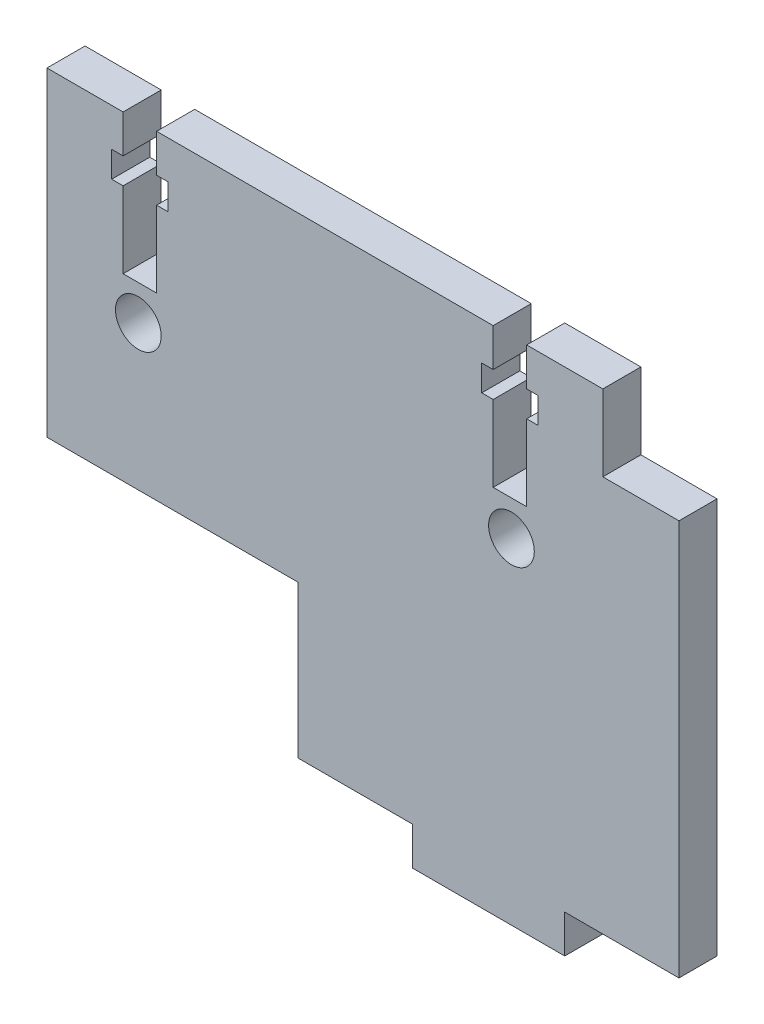
from build123d import *

# Parameters (mm, degrees)
BOSS_EXTRUDE1_DEPTH = 5
SKETCH2_W           = 33
SKETCH2_H           = 20
SKETCH2_W_2         = 10
SKETCH2_H_2         = 10
CUT_EXTRUDE1_DEPTH  = 5
CUT_EXTRUDE2_DEPTH  = 10
SKETCH4_R           = 3
CUT_EXTRUDE3_DEPTH  = 10


with BuildPart() as part:
    # Sketch1 → Boss-Extrude1 (new body)
    with BuildSketch(Plane.XY):
        Polygon((26.5, -31), (26.5, -36), (6.5, -36), (6.5, -31), (-41.5, -31), (-41.5, 31), (41.5, 31), (41.5, -31), align=None)
    extrude(amount=BOSS_EXTRUDE1_DEPTH)

    # Sketch2 → Cut-Extrude1 (cut)
    with BuildSketch(Plane(origin=(0, 0, 0), x_dir=(-1, 0, 0), z_dir=(0, 0, -1))):
        with Locations((25, -21)):
            Rectangle(SKETCH2_W, SKETCH2_H)
        with Locations((-36.5, 26)):
            Rectangle(SKETCH2_W_2, SKETCH2_H_2)
    extrude(amount=-CUT_EXTRUDE1_DEPTH, mode=Mode.SUBTRACT)

    # Sketch3 → Cut-Extrude2 (cut)
    with BuildSketch(Plane(origin=(0, 0, 0), x_dir=(-1, 0, 0), z_dir=(0, 0, -1))):
        Polygon((31.5, 22.6), (31.5, 12.6), (27.1, 12.6), (27.1, 22.6), (25.6, 22.6), (25.6, 26), (27.1, 26), (27.1, 31), (31.5, 31), (31.5, 26), (33, 26), (33, 22.6), align=None)
        Polygon((-17.1, 22.6), (-17.1, 12.6), (-21.5, 12.6), (-21.5, 22.6), (-23, 22.6), (-23, 26), (-21.5, 26), (-21.5, 31), (-17.1, 31), (-17.1, 26), (-15.6, 26), (-15.6, 22.6), align=None)
    extrude(amount=-CUT_EXTRUDE2_DEPTH, mode=Mode.SUBTRACT)

    # Sketch4 → Cut-Extrude3 (cut)
    with BuildSketch(Plane(origin=(0, 0, 0), x_dir=(-1, 0, 0), z_dir=(0, 0, -1))):
        with Locations((29.5, 8)):
            Circle(SKETCH4_R)
        with Locations((-19.5, 8)):
            Circle(SKETCH4_R)
    extrude(amount=-CUT_EXTRUDE3_DEPTH, mode=Mode.SUBTRACT)


solid = part.part
